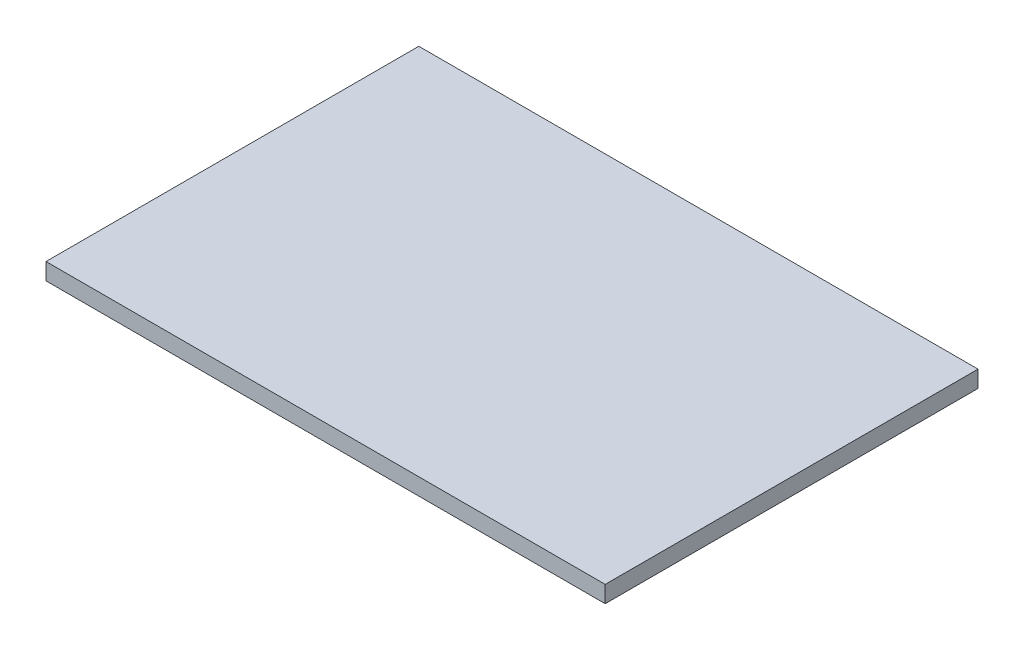
from build123d import *

# Parameters (mm, degrees)
SKETCH_1_W      = 300
SKETCH_1_H      = 200
EXTRUDE_1_DEPTH = 9


with BuildPart() as part:
    # 草图1 → 凸台-拉伸1 (new body)
    with BuildSketch(Plane(origin=(0, 0, 0), x_dir=(1, 0, 0), z_dir=(0, 1, 0))):
        Rectangle(SKETCH_1_W, SKETCH_1_H)
    extrude(amount=EXTRUDE_1_DEPTH)


solid = part.part
